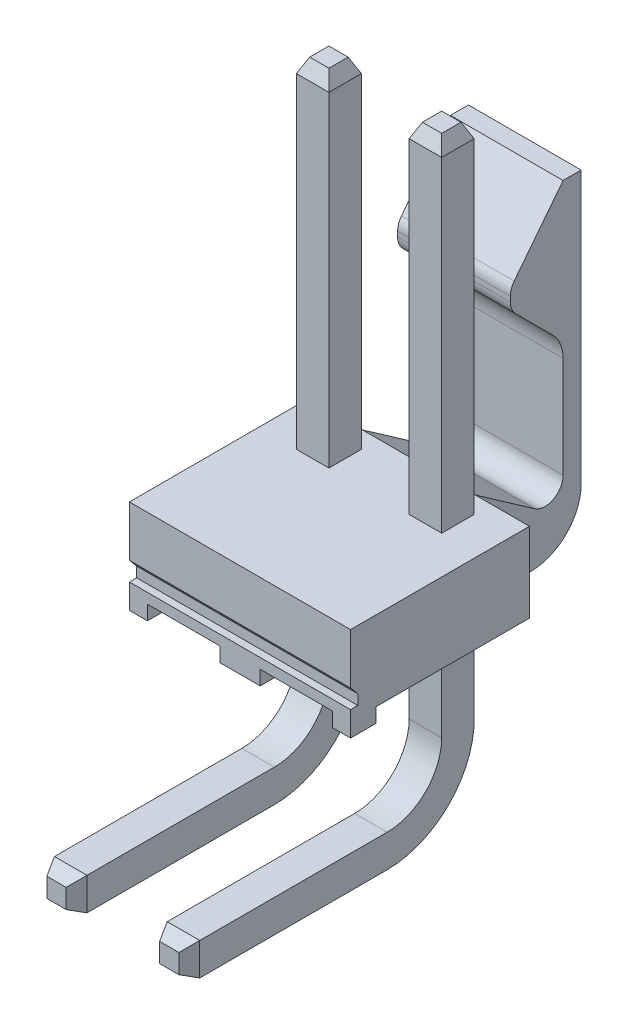
from build123d import *

# Parameters (mm, degrees)
BOSS_EXTRUDE14_DEPTH           = 3.885
BOSS_EXTRUDE14_DEPTH_BACK      = 3.885
BOSS_EXTRUDE15_DEPTH           = 1.98
BOSS_EXTRUDE15_DEPTH_BACK      = 1.98
SKETCH19_W                     = 2.54
SKETCH19_H                     = 0.508
CUT_EXTRUDE4_DEPTH             = 14.676350336
SKETCH20_W                     = 1.143
SKETCH20_H                     = 1.143
CUT_EXTRUDE5_DEPTH             = 17.713250759
SKETCH20_2_W                   = 1.143
SKETCH20_2_H                   = 1.143
SKETCH23_W                     = 1.143
SKETCH23_H                     = 1.143
BOSS_EXTRUDE16_DEPTH           = 0.5
BOSS_EXTRUDE16_DRAFT           = 25
BOSS_EXTRUDE16_PROFILE_2_DEPTH = 0.5
BOSS_EXTRUDE16_PROFILE_2_DRAFT = 25
SKETCH24_W                     = 1.143
SKETCH24_H                     = 1.143
BOSS_EXTRUDE17_DEPTH           = 0.5
BOSS_EXTRUDE17_DRAFT           = 25
BOSS_EXTRUDE17_PROFILE_2_DEPTH = 0.5
BOSS_EXTRUDE17_PROFILE_2_DRAFT = 25


with BuildPart() as part:
    # Sketch17 → Boss-Extrude14 (new, two sides: drawn at the far end of the back side and taken through both)
    with BuildSketch(Plane(origin=(0, 0, 0), x_dir=(0, 0, -1), z_dir=(1, 0, 0)).offset(-BOSS_EXTRUDE14_DEPTH_BACK)):
        Polygon((-2.88925001, -0.683705401), (-2.88925001, -1.039305413), (-3.14325, -1.039305413), (-3.14325, -1.905), (-2.25425, -1.905), (-2.25425, -1.397), (3.14325, -1.397), (3.14325, 1.397), (-3.14325, 1.397), (-3.14325, -0.381), align=None)
    extrude(amount=BOSS_EXTRUDE14_DEPTH + BOSS_EXTRUDE14_DEPTH_BACK)

    # Sketch18 → Boss-Extrude15 (add, two sides: drawn at the far end of the back side and taken through both)
    with BuildSketch(Plane(origin=(0, 0, 0), x_dir=(0, 0, -1), z_dir=(1, 0, 0)).offset(-BOSS_EXTRUDE15_DEPTH_BACK)):
        with BuildLine():
            Line((6.22935, 9.4234), (4.509763171, 7.222429228))
            ThreePointArc((4.509763171, 7.222429228), (4.409745704, 7.038219969), (4.37515, 6.831484191))
            Line((4.37515, 6.831484191), (4.37515, 6.655190003))
            ThreePointArc((4.37515, 6.655190003), (4.423486497, 6.412186024), (4.561137194, 6.206177197))
            Line((4.561137194, 6.206177197), (5.857375612, 4.909938779))
            ThreePointArc((5.857375612, 4.909938779), (6.132677006, 4.497921126), (6.22935, 4.011913167))
            Line((6.22935, 4.011913167), (6.22935, 0.455913167))
            ThreePointArc((6.22935, 0.455913167), (5.887560369, -0.107338712), (5.230128963, -0.064248381))
            Line((5.230128963, -0.064248381), (3.14325, 1.397))
            Line((3.14325, 1.397), (3.14325, -1.905))
            Line((3.14325, -1.905), (5.08635, -1.905))
            ThreePointArc((5.08635, -1.905), (6.343585857, -1.384235857), (6.86435, -0.127))
            Line((6.86435, -0.127), (6.86435, 9.4234))
            Line((6.86435, 9.4234), (6.22935, 9.4234))
        make_face()
    extrude(amount=BOSS_EXTRUDE15_DEPTH + BOSS_EXTRUDE15_DEPTH_BACK)

    # Sketch19 → Cut-Extrude4 (cut, through all)
    with BuildSketch(Plane(origin=(0, 0, 2.25425), x_dir=(-1, 0, 0), z_dir=(0, 0, -1))):
        with Locations((-1.98, -1.651)):
            Rectangle(SKETCH19_W, SKETCH19_H)
        with Locations((1.98, -1.651)):
            Rectangle(SKETCH19_W, SKETCH19_H)
    extrude(amount=-CUT_EXTRUDE4_DEPTH, mode=Mode.SUBTRACT)

    # Sketch20 → Cut-Extrude5 (cut, through all)
    with BuildSketch(Plane(origin=(0, 12.83, 0), x_dir=(1, 0, 0), z_dir=(0, 1, 0))):
        with Locations((-1.9812, 1.96215)):
            Rectangle(SKETCH20_W, SKETCH20_H)
        with Locations((1.9812, 1.96215)):
            Rectangle(SKETCH20_W, SKETCH20_H)
    extrude(amount=-CUT_EXTRUDE5_DEPTH, mode=Mode.SUBTRACT)


with BuildPart() as body_2:
    # Sweep1: sweep along a path in Sketch21
    with BuildLine(Plane(origin=(1.98, 0, 0), x_dir=(0, 0, -1), z_dir=(1, 0, 0))) as sweep1_path:
        Line((1.96215, 12.83), (1.96215, -4.8275))
        ThreePointArc((1.96215, -4.8275), (1.23351954, -6.58656954), (-0.52555, -7.3152))
        Line((-0.52555, -7.3152), (-7.11, -7.3152))
    # Sketch20_2 → Sweep1 (sweep)
    with BuildSketch(Plane(origin=(0, 12.83, 0), x_dir=(1, 0, 0), z_dir=(0, 1, 0))):
        with Locations((-1.9812, 1.96215)):
            Rectangle(SKETCH20_2_W, SKETCH20_2_H)
        with Locations((1.9812, 1.96215)):
            Rectangle(SKETCH20_2_W, SKETCH20_2_H)
    sweep(path=sweep1_path.line)


with BuildPart() as boss_extrude16_tool:
    # Sketch23 → Boss-Extrude16 (with draft: the straight prism first)
    with BuildSketch(Plane(origin=(0, 12.83, 0), x_dir=(1, 0, 0), z_dir=(0, 1, 0))):
        with Locations((1.9812, 1.96215)):
            Rectangle(SKETCH23_W, SKETCH23_H)
    extrude(amount=BOSS_EXTRUDE16_DEPTH)
    # Boss-Extrude16: the draft: its side faces are tilted about the plane it starts from
    boss_extrude16_sides = [boss_extrude16_tool.faces().sort_by_distance(p)[0] for p in [
        (1.9812, 13.08, -1.39065),
        (2.5527, 13.08, -1.96215),
        (1.9812, 13.08, -2.53365),
        (1.4097, 13.08, -1.96215),
    ]]
    draft(boss_extrude16_sides, Plane(origin=(0, 12.83, 0), x_dir=(1, 0, 0), z_dir=(0, 1, 0)), BOSS_EXTRUDE16_DRAFT)


with BuildPart() as body_2_1:
    add(body_2.part)

    # Boss-Extrude16: add boss_extrude16_tool
    add(boss_extrude16_tool.part)


with BuildPart() as boss_extrude16_profile_2_tool:
    # Sketch23 → Boss-Extrude16 profile 2 (with draft: the straight prism first)
    with BuildSketch(Plane(origin=(0, 12.83, 0), x_dir=(1, 0, 0), z_dir=(0, 1, 0))):
        with Locations((-1.9812, 1.96215)):
            Rectangle(SKETCH23_W, SKETCH23_H)
    extrude(amount=BOSS_EXTRUDE16_PROFILE_2_DEPTH)
    # Boss-Extrude16 profile 2: the draft: its side faces are tilted about the plane it starts from
    boss_extrude16_profile_2_sides = [boss_extrude16_profile_2_tool.faces().sort_by_distance(p)[0] for p in [
        (-1.9812, 13.08, -1.39065),
        (-1.4097, 13.08, -1.96215),
        (-1.9812, 13.08, -2.53365),
        (-2.5527, 13.08, -1.96215),
    ]]
    draft(boss_extrude16_profile_2_sides, Plane(origin=(0, 12.83, 0), x_dir=(1, 0, 0), z_dir=(0, 1, 0)), BOSS_EXTRUDE16_PROFILE_2_DRAFT)


with BuildPart() as body_2_2:
    add(body_2_1.part)

    # Boss-Extrude16 profile 2: add boss_extrude16_profile_2_tool
    add(boss_extrude16_profile_2_tool.part)


with BuildPart() as boss_extrude17_tool:
    # Sketch24 → Boss-Extrude17 (with draft: the straight prism first)
    with BuildSketch(Plane.XY.offset(7.11)):
        with Locations((1.9812, -7.3152)):
            Rectangle(SKETCH24_W, SKETCH24_H)
    extrude(amount=BOSS_EXTRUDE17_DEPTH)
    # Boss-Extrude17: the draft: its side faces are tilted about the plane it starts from
    boss_extrude17_sides = [boss_extrude17_tool.faces().sort_by_distance(p)[0] for p in [
        (1.9812, -6.7437, 7.36),
        (1.4097, -7.3152, 7.36),
        (1.9812, -7.8867, 7.36),
        (2.5527, -7.3152, 7.36),
    ]]
    draft(boss_extrude17_sides, Plane.XY.offset(7.11), BOSS_EXTRUDE17_DRAFT)


with BuildPart() as body_2_3:
    add(body_2_2.part)

    # Boss-Extrude17: add boss_extrude17_tool
    add(boss_extrude17_tool.part)


with BuildPart() as boss_extrude17_profile_2_tool:
    # Sketch24 → Boss-Extrude17 profile 2 (with draft: the straight prism first)
    with BuildSketch(Plane.XY.offset(7.11)):
        with Locations((-1.9812, -7.3152)):
            Rectangle(SKETCH24_W, SKETCH24_H)
    extrude(amount=BOSS_EXTRUDE17_PROFILE_2_DEPTH)
    # Boss-Extrude17 profile 2: the draft: its side faces are tilted about the plane it starts from
    boss_extrude17_profile_2_sides = [boss_extrude17_profile_2_tool.faces().sort_by_distance(p)[0] for p in [
        (-1.9812, -6.7437, 7.36),
        (-2.5527, -7.3152, 7.36),
        (-1.9812, -7.8867, 7.36),
        (-1.4097, -7.3152, 7.36),
    ]]
    draft(boss_extrude17_profile_2_sides, Plane.XY.offset(7.11), BOSS_EXTRUDE17_PROFILE_2_DRAFT)


with BuildPart() as body_2_4:
    add(body_2_3.part)

    # Boss-Extrude17 profile 2: add boss_extrude17_profile_2_tool
    add(boss_extrude17_profile_2_tool.part)


solid = Compound([part.part, body_2_4.part])
